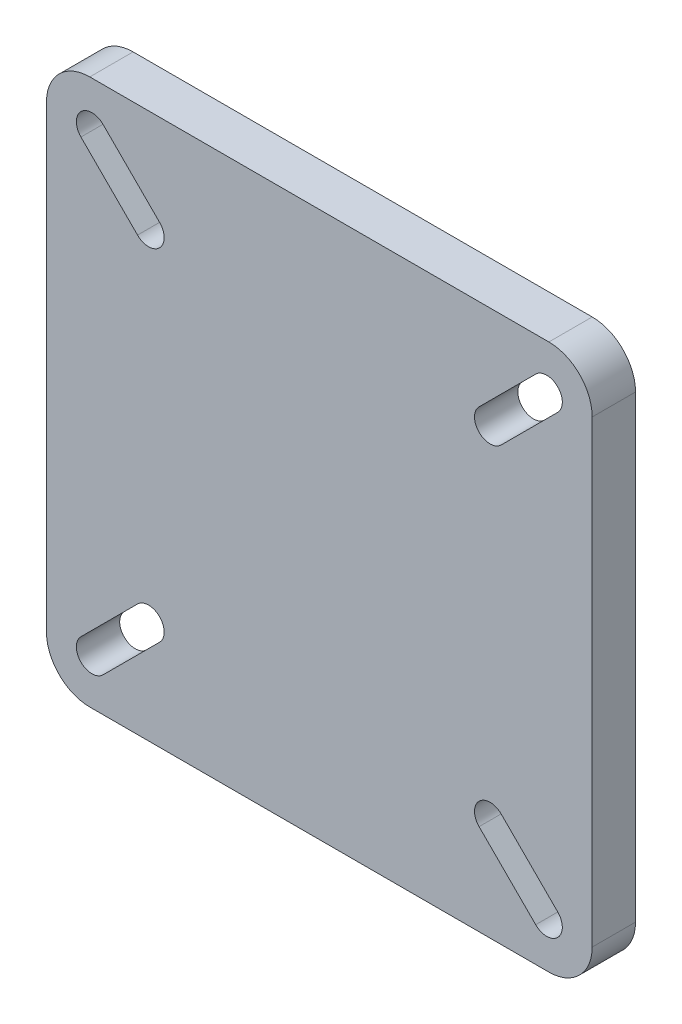
from build123d import *

# Parameters (mm, degrees)
SKETCH2_W           = 120
SKETCH2_H           = 120
BOSS_EXTRUDE1_DEPTH = 9.525
CUT_EXTRUDE1_DEPTH  = 86.385746029
CIRPATTERN1_COUNT   = 4
FILLET1_R           = 9.525


with BuildPart() as part:
    # Sketch2 → Boss-Extrude1 (new body)
    with BuildSketch(Plane.XY):
        Rectangle(SKETCH2_W, SKETCH2_H)
    extrude(amount=BOSS_EXTRUDE1_DEPTH)

    # Sketch3 → Cut-Extrude1 (cut, symmetric)
    with BuildSketch(Plane.XY.offset(9.525)):
        with BuildLine():
            Line((-47.575330847, 52.424669153), (-35.125330847, 39.974669153))
            ThreePointArc((-35.125330847, 39.974669153), (-35.125330847, 35.125330847), (-39.974669153, 35.125330847))
            Line((-39.974669153, 35.125330847), (-52.424669153, 47.575330847))
            ThreePointArc((-52.424669153, 47.575330847), (-52.424669153, 52.424669153), (-47.575330847, 52.424669153))
        make_face()
    cut_extrude1 = extrude(amount=CUT_EXTRUDE1_DEPTH, both=True, mode=Mode.SUBTRACT)

    # CirPattern1: Cut-Extrude1 ×4 about axis
    cirpattern1_axis = Axis((0, 0, 0), (0, 0, 1))
    for i in range(1, CIRPATTERN1_COUNT):
        add(cut_extrude1.rotate(cirpattern1_axis, i * 360 / CIRPATTERN1_COUNT), mode=Mode.SUBTRACT)

    # Fillet1
    fillet1_edges = [part.edges().sort_by_distance(p)[0] for p in [
        (60, -60, 4.7625),
        (60, 60, 4.7625),
        (-60, -60, 4.7625),
        (-60, 60, 4.7625),
    ]]
    fillet(fillet1_edges, radius=FILLET1_R)


solid = part.part
